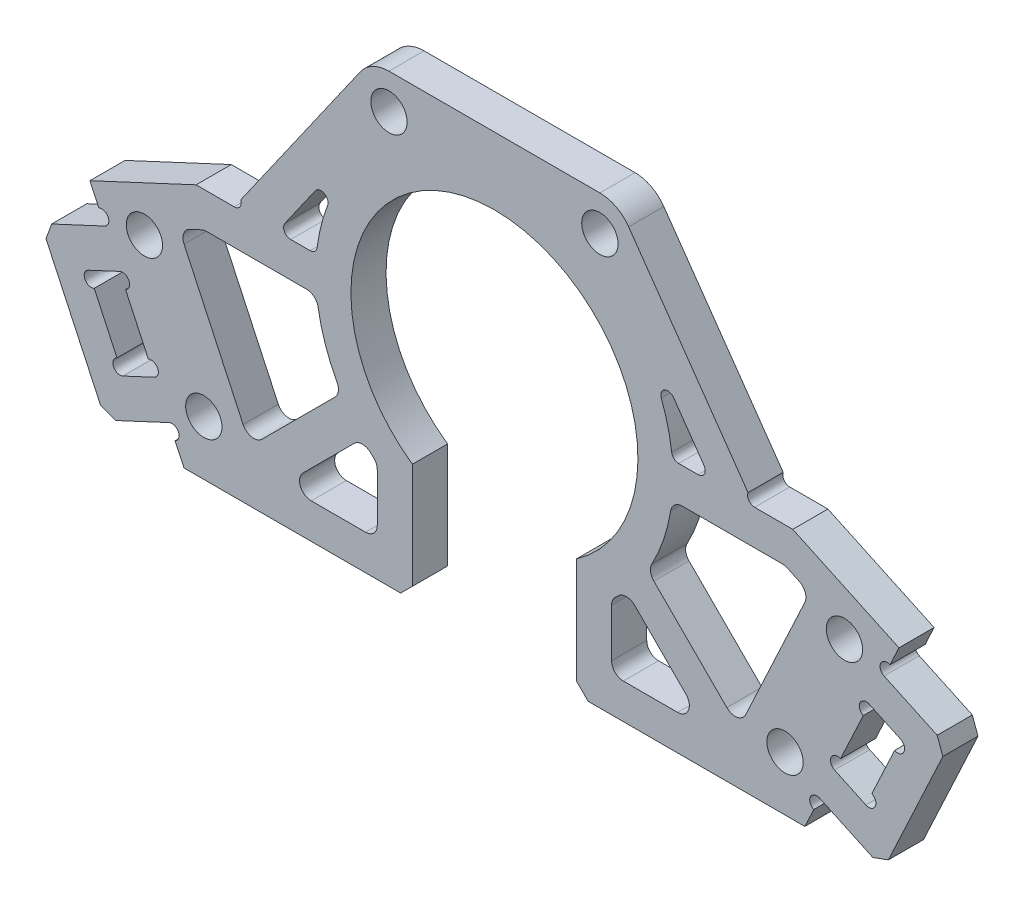
from build123d import *

# Parameters (mm, degrees)
EXTRUDE_1_DEPTH     = 1.5
EXTRUDE_2_DEPTH     = 3
SKETCH_3_R          = 0.6
CUT_EXTRUDE_1_DEPTH = 4
SKETCH_4_R          = 1.55
CUT_EXTRUDE_2_DEPTH = 4
CUT_EXTRUDE_5_DEPTH = 4
SKETCH_9_R          = 12.25
CUT_EXTRUDE_6_DEPTH = 4
EXTRUDE_4_DEPTH     = 3
SKETCH_12_R         = 1.55
EXTRUDE_5_DEPTH     = 3
SKETCH_13_W         = 14
SKETCH_13_H         = 10.026263385
CUT_EXTRUDE_7_DEPTH = 4
SKETCH_14_W         = 3
SKETCH_14_H         = 10.026263385
EXTRUDE_6_DEPTH     = 3
FILLET_1_R          = 1
CHAMFER_1_SIZE      = 1
SKETCH_15_R         = 0.6
CUT_EXTRUDE_8_DEPTH = 4
CUT_EXTRUDE_9_DEPTH = 4
FILLET_2_R          = 0.6


with BuildPart() as part:
    # 草图1 → 凸台-拉伸1 (new body, symmetric)
    with BuildSketch(Plane.XY):
        Polygon((-34.52642222, 8.609923977), (-26.496675247, -8.609923977), (26.496675247, -8.609923977), (34.52642222, 8.609923977), (25.463344349, 12.836106594), (-25.463344349, 12.836106594), align=None)
    extrude(amount=EXTRUDE_1_DEPTH, both=True)

    # 草图2 → 凸台-拉伸2 (add)
    with BuildSketch(Plane.XY.offset(1.5)):
        Polygon((-33.258567434, 5.891000616), (-38.696414157, 3.355291045), (-33.202376754, -8.426710186), (-27.764530032, -5.891000616), (-29.032384817, -3.172077255), (-31.705992789, -4.418801127), (-34.664320621, 1.925353382), (-31.990712649, 3.172077255), align=None)
        Polygon((38.696414157, 3.355291045), (33.202376754, -8.426710186), (27.764530032, -5.891000616), (29.032384817, -3.172077255), (31.705992789, -4.418801127), (34.664320621, 1.925353382), (31.990712649, 3.172077255), (33.258567434, 5.891000616), align=None)
    extrude(amount=-EXTRUDE_2_DEPTH)

    # 草图3 → 切除-拉伸1 (cut, through all)
    with BuildSketch(Plane.XY.offset(1.5)):
        with Locations((-33.512138391, 6.434785288)):
            Circle(SKETCH_3_R)
        with Locations((-34.410749664, 1.38156871)):
            Circle(SKETCH_3_R)
        with Locations((-31.959563746, -3.875016455)):
            Circle(SKETCH_3_R)
        with Locations((-29.285955774, -2.628292582)):
            Circle(SKETCH_3_R)
        with Locations((-31.737141692, 2.628292582)):
            Circle(SKETCH_3_R)
        with Locations((-27.510959075, -6.434785288)):
            Circle(SKETCH_3_R)
        with Locations((27.510959075, -6.434785288)):
            Circle(SKETCH_3_R)
        with Locations((31.737141692, 2.628292582)):
            Circle(SKETCH_3_R)
        with Locations((29.285955774, -2.628292582)):
            Circle(SKETCH_3_R)
        with Locations((31.959563746, -3.875016455)):
            Circle(SKETCH_3_R)
        with Locations((34.410749664, 1.38156871)):
            Circle(SKETCH_3_R)
        with Locations((33.512138391, 6.434785288)):
            Circle(SKETCH_3_R)
    extrude(amount=-CUT_EXTRUDE_1_DEPTH, mode=Mode.SUBTRACT)

    # 草图4 → 切除-拉伸2 (cut, through all)
    with BuildSketch(Plane.XY.offset(1.5)):
        with Locations((-29.875181049, 6.917010638)):
            Circle(SKETCH_4_R)
        with Locations((-24.803761908, -3.958682806)):
            Circle(SKETCH_4_R)
        with Locations((24.803761908, -3.958682806)):
            Circle(SKETCH_4_R)
        with Locations((29.875181049, 6.917010638)):
            Circle(SKETCH_4_R)
    extrude(amount=-CUT_EXTRUDE_2_DEPTH, mode=Mode.SUBTRACT)

    # 草图5 → 切除-拉伸5 (cut, through all)
    with BuildSketch(Plane.XY.offset(1.5)):
        Polygon((-24.798260361, 9.836106594), (-6.847242561, 9.836106594), (-20.846564229, -4.163215074), (-26.914412925, 8.849328448), align=None)
        Polygon((26.914412925, 8.849328448), (20.846564229, -4.163215074), (6.847242561, 9.836106594), (24.798260361, 9.836106594), align=None)
        Polygon((18.050632445, -5.609923977), (-18.050632445, -5.609923977), (-2.604601874, 9.836106594), (2.604601874, 9.836106594), align=None)
    extrude(amount=-CUT_EXTRUDE_5_DEPTH, mode=Mode.SUBTRACT)

    # 草图9 → 切除-拉伸6 (cut, through all)
    with BuildSketch(Plane.XY.offset(1.5)):
        with Locations((0, 11.469324039)):
            Circle(SKETCH_9_R)
    extrude(amount=-CUT_EXTRUDE_6_DEPTH, mode=Mode.SUBTRACT)

    # 草图10 → 凸台-拉伸4 (add)
    with BuildSketch(Plane.XY.offset(1.5)):
        with BuildLine():
            Line((-12.173512453, 12.836106594), (-15.188627504, 12.836106594))
            ThreePointArc((-15.188627504, 12.836106594), (0, -3.780675961), (15.188627504, 12.836106594))
            Line((15.188627504, 12.836106594), (12.173512453, 12.836106594))
            ThreePointArc((12.173512453, 12.836106594), (0, -0.780675961), (-12.173512453, 12.836106594))
        make_face()
    extrude(amount=-EXTRUDE_4_DEPTH)

    # 草图12 → 凸台-拉伸5 (add)
    with BuildSketch(Plane(origin=(0, 0, -1.5), x_dir=(-1, 0, 0), z_dir=(0, 0, -1))):
        with BuildLine():
            Line((-11.457456133, 28.190053348), (-22.208405391, 12.836106594))
            Line((-22.208405391, 12.836106594), (-12.173512453, 12.836106594))
            ThreePointArc((-12.173512453, 12.836106594), (0, 23.719324039), (12.173512453, 12.836106594))
            Line((12.173512453, 12.836106594), (22.208405391, 12.836106594))
            Line((22.208405391, 12.836106594), (11.457456133, 28.190053348))
            ThreePointArc((11.457456133, 28.190053348), (10.38524584, 29.130356539), (9, 29.469324039))
            Line((9, 29.469324039), (-9, 29.469324039))
            ThreePointArc((-9, 29.469324039), (-10.38524584, 29.130356539), (-11.457456133, 28.190053348))
        make_face()
        with Locations((-9, 26.469324039)):
            Circle(SKETCH_12_R, mode=Mode.SUBTRACT)
        with Locations((9, 26.469324039)):
            Circle(SKETCH_12_R, mode=Mode.SUBTRACT)
    extrude(amount=-EXTRUDE_5_DEPTH)

    # 草图13 → 切除-拉伸7 (cut, through all)
    with BuildSketch(Plane(origin=(0, 0, -1.5), x_dir=(-1, 0, 0), z_dir=(0, 0, -1))):
        with Locations((0, -3.596792285)):
            Rectangle(SKETCH_13_W, SKETCH_13_H)
    extrude(amount=-CUT_EXTRUDE_7_DEPTH, mode=Mode.SUBTRACT)

    # 草图14 → 凸台-拉伸6 (add)
    with BuildSketch(Plane(origin=(0, 0, -1.5), x_dir=(-1, 0, 0), z_dir=(0, 0, -1))):
        with Locations((-8.5, -3.596792285)):
            Rectangle(SKETCH_14_W, SKETCH_14_H)
        with Locations((8.5, -3.596792285)):
            Rectangle(SKETCH_14_W, SKETCH_14_H)
    extrude(amount=-EXTRUDE_6_DEPTH)

    # 圆角1
    fillet_1_edges = [part.edges().sort_by_distance(p)[0] for p in [
        (24.798260361, 9.836106594, 0),
        (26.914412925, 8.849328448, 0),
        (20.846564229, -4.163215074, 0),
        (18.050632445, -5.609923977, 0),
        (-18.050632445, -5.609923977, 0),
        (-26.914412925, 8.849328448, 0),
        (-24.798260361, 9.836106594, 0),
        (-20.846564229, -4.163215074, 0),
        (15.162292069, 9.836106594, 0),
        (-15.162292069, 9.836106594, 0),
        (11.258127086, 1.182581381, 0),
        (13.070507936, 3.612841219, 0),
        (-13.070507936, 3.612841219, 0),
        (-11.258127086, 1.182581381, 0),
        (10, -0.044254901, 0),
        (10, -5.609923977, 0),
        (-10, -0.044254901, 0),
        (-10, -5.609923977, 0),
    ]]
    fillet(fillet_1_edges, radius=FILLET_1_R)

    # 倒角1
    chamfer_1_edges = [part.edges().sort_by_distance(p)[0] for p in [
        (-33.202376754, -8.426710186, 0),
        (-38.696414157, 3.355291045, 0),
        (7, -8.609923977, 0),
        (-7, -8.609923977, 0),
        (38.696414157, 3.355291045, 0),
        (33.202376754, -8.426710186, 0),
    ]]
    chamfer(chamfer_1_edges, length=CHAMFER_1_SIZE)

    # 草图15 → 切除-拉伸8 (cut, through all)
    with BuildSketch(Plane.XY.offset(1.5)):
        with Locations((-22.208405391, 13.436106594)):
            Circle(SKETCH_15_R)
        with Locations((22.208405391, 13.436106594)):
            Circle(SKETCH_15_R)
    extrude(amount=-CUT_EXTRUDE_8_DEPTH, mode=Mode.SUBTRACT)

    # 草图16 → 切除-拉伸9 (cut, through all)
    with BuildSketch(Plane.XY.offset(1.5)):
        with BuildLine():
            Line((-18.546081625, 12.836106594), (-15.188627504, 12.836106594))
            ThreePointArc((-15.188627504, 12.836106594), (-14.856302935, 14.912108248), (-14.241610553, 16.922674279))
            ThreePointArc((-14.241610553, 16.922674279), (-14.520472082, 17.66711716), (-15.293427441, 17.481378183))
            Line((-15.293427441, 17.481378183), (-18.546081625, 12.836106594))
        make_face()
        with BuildLine():
            Line((18.546081625, 12.836106594), (15.188627504, 12.836106594))
            ThreePointArc((15.188627504, 12.836106594), (14.856302935, 14.912108248), (14.241610553, 16.922674279))
            ThreePointArc((14.241610553, 16.922674279), (14.520472082, 17.66711716), (15.293427441, 17.481378183))
            Line((15.293427441, 17.481378183), (18.546081625, 12.836106594))
        make_face()
    extrude(amount=-CUT_EXTRUDE_9_DEPTH, mode=Mode.SUBTRACT)

    # 圆角2
    fillet_2_edges = [part.edges().sort_by_distance(p)[0] for p in [
        (-15.188627504, 12.836106594, 0),
        (-18.546081625, 12.836106594, 0),
        (15.188627504, 12.836106594, 0),
        (18.546081625, 12.836106594, 0),
    ]]
    fillet(fillet_2_edges, radius=FILLET_2_R)


solid = part.part
